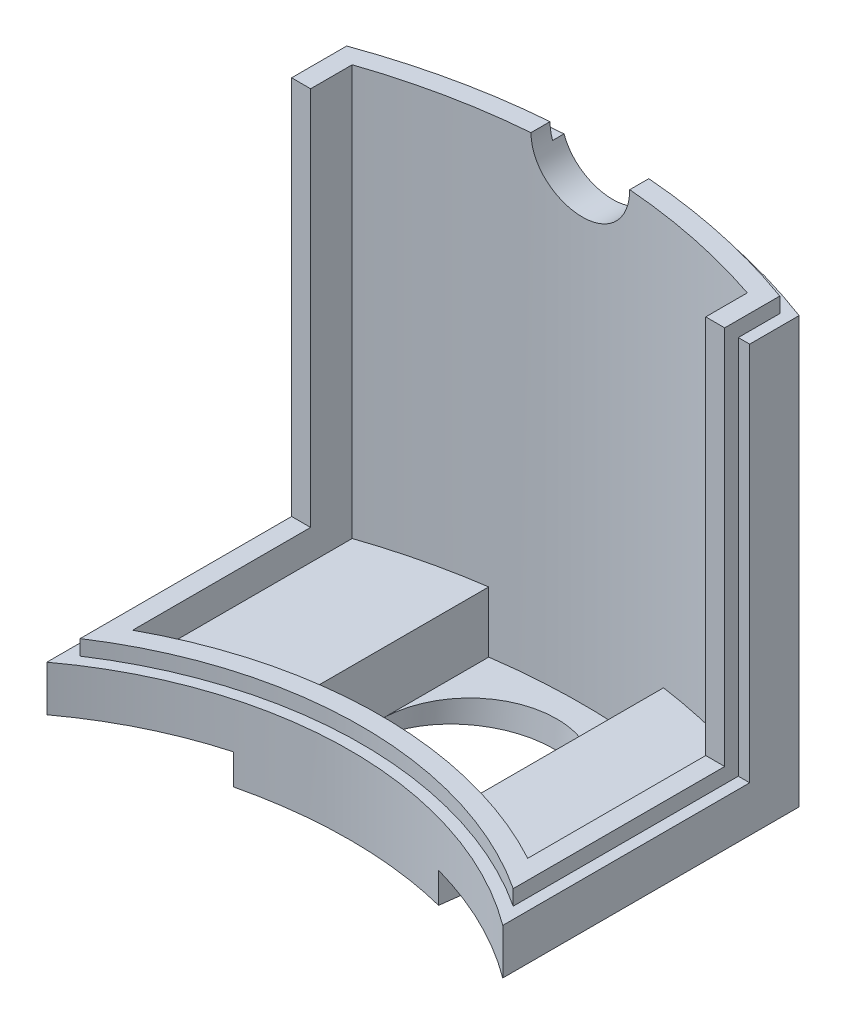
from build123d import *

# Parameters (mm, degrees)
BOSS_EXTRUDE2_DEPTH      = 2
BOSS_EXTRUDE4_DEPTH      = 4
CUT_EXTRUDE6_DEPTH       = 22.75
SKETCH4_R                = 5.75
CUT_EXTRUDE7_DEPTH       = 2
CUT_EXTRUDE8_DEPTH       = 4
BOSS_EXTRUDE5_DEPTH      = 27
BOSS_EXTRUDE6_DEPTH      = 2
BOSS_EXTRUDE7_DEPTH      = 2
BOSS_EXTRUDE8_DEPTH      = 25
CUT_EXTRUDE10_DEPTH      = 26
SKETCH14_R               = 3.25
CUT_EXTRUDE11_DEPTH      = 1
CUT_EXTRUDE11_DEPTH_BACK = 43.5
CUT_EXTRUDE12_DEPTH      = 1


with BuildPart() as part:
    # Sketch1 → Boss-Extrude2 (new body)
    with BuildSketch(Plane(origin=(0, 0, 0), x_dir=(1, 0, 0), z_dir=(0, 1, 0))):
        with BuildLine():
            Line((-15, 39.764934301), (-15, 20.264934301))
            ThreePointArc((-15, 20.264934301), (0, 25.212448557), (15, 20.264934301))
            Line((15, 20.264934301), (15, 39.764934301))
            ThreePointArc((15, 39.764934301), (0, 42.5), (-15, 39.764934301))
        make_face()
    extrude(amount=BOSS_EXTRUDE2_DEPTH)

    # Sketch2 → Boss-Extrude4 (add)
    with BuildSketch(Plane.XZ):
        with BuildLine():
            Line((6.75, -24.292078179), (6.75, -41.960546946))
            ThreePointArc((6.75, -41.960546946), (0, -42.5), (-6.75, -41.960546946))
            Line((-6.75, -41.960546946), (-6.75, -24.292078179))
            ThreePointArc((-6.75, -24.292078179), (0, -25.212448557), (6.75, -24.292078179))
        make_face()
    extrude(amount=BOSS_EXTRUDE4_DEPTH)

    # Sketch3 → Cut-Extrude6 (cut, through all)
    with BuildSketch(Plane(origin=(6.75, 0, 0), x_dir=(0, 0, -1), z_dir=(1, 0, 0))):
        Polygon((41.960546946, -4), (24.292078179, -2), (24.292078179, -4), align=None)
    extrude(amount=-CUT_EXTRUDE6_DEPTH, mode=Mode.SUBTRACT)

    # Sketch4 → Cut-Extrude7 (cut)
    with BuildSketch(Plane(origin=(0, 0.740280631, -0.083796807), x_dir=(-1, 0, 0), z_dir=(0, -0.993654251, 0.112477687))):
        with Locations((0, 33.039130231)):
            Circle(SKETCH4_R)
    extrude(amount=-CUT_EXTRUDE7_DEPTH, mode=Mode.SUBTRACT)

    # Sketch5 → Cut-Extrude8 (cut)
    with BuildSketch(Plane(origin=(0, 2, 0), x_dir=(1, 0, 0), z_dir=(0, 1, 0))):
        with BuildLine():
            ThreePointArc((-5.75, 40.089743077), (0, 40.5), (5.75, 40.089743077))
            Line((5.75, 40.089743077), (5.75, 26.598023544))
            ThreePointArc((5.75, 26.598023544), (0, 27.212448557), (-5.75, 26.598023544))
            Line((-5.75, 26.598023544), (-5.75, 40.089743077))
        make_face()
    extrude(amount=-CUT_EXTRUDE8_DEPTH, mode=Mode.SUBTRACT)

    # Sketch7 → Boss-Extrude5 (add)
    with BuildSketch(Plane(origin=(0, 2, 0), x_dir=(1, 0, 0), z_dir=(0, 1, 0))):
        with BuildLine():
            Line((-15, 37.619808612), (-15, 39.764934301))
            ThreePointArc((-15, 39.764934301), (0, 42.5), (15, 39.764934301))
            Line((15, 39.764934301), (15, 37.619808612))
            ThreePointArc((15, 37.619808612), (0, 40.5), (-15, 37.619808612))
        make_face()
    extrude(amount=BOSS_EXTRUDE5_DEPTH)

    # Sketch8 → Boss-Extrude6 (add)
    with BuildSketch(Plane(origin=(0, 2, 0), x_dir=(1, 0, 0), z_dir=(0, 1, 0))):
        with BuildLine():
            Line((-15, 22.7050073), (-15, 20.264934301))
            ThreePointArc((-15, 20.264934301), (0, 25.212448557), (15, 20.264934301))
            Line((15, 20.264934301), (15, 22.7050073))
            ThreePointArc((15, 22.7050073), (0, 27.212448557), (-15, 22.7050073))
        make_face()
    extrude(amount=BOSS_EXTRUDE6_DEPTH)

    # Sketch9 → Boss-Extrude7 (add)
    with BuildSketch(Plane(origin=(0, 2, 0), x_dir=(1, 0, 0), z_dir=(0, 1, 0))):
        with BuildLine():
            Line((-15, 37.619808612), (-15, 22.7050073))
            ThreePointArc((-15, 22.7050073), (-14.012881704, 23.32716234), (-13, 23.906429187))
            Line((-13, 23.906429187), (-13, 38.356876828))
            ThreePointArc((-13, 38.356876828), (-14.004849781, 38.001502373), (-15, 37.619808612))
        make_face()
    boss_extrude7 = extrude(amount=BOSS_EXTRUDE7_DEPTH)

    # Mirror1: Boss-Extrude7 across plane
    add(boss_extrude7.mirror(Plane(origin=(0, 0, 0), x_dir=(0, 0, 1), z_dir=(1, 0, 0))))

    # Sketch12 → Boss-Extrude8 (add)
    with BuildSketch(Plane(origin=(0, 4, 0), x_dir=(1, 0, 0), z_dir=(0, 1, 0))):
        with BuildLine():
            ThreePointArc((-13, 38.356876828), (-14.004849781, 38.001502373), (-15, 37.619808612))
            Line((-15, 37.619808612), (-15, 35.619808612))
            Line((-15, 35.619808612), (-13, 35.619808612))
            Line((-13, 35.619808612), (-13, 38.356876828))
        make_face()
        with BuildLine():
            Line((15, 35.619808612), (15, 37.619808612))
            ThreePointArc((15, 37.619808612), (14.004849781, 38.001502373), (13, 38.356876828))
            Line((13, 38.356876828), (13, 35.619808612))
            Line((13, 35.619808612), (15, 35.619808612))
        make_face()
    extrude(amount=BOSS_EXTRUDE8_DEPTH)

    # Sketch13 → Cut-Extrude10 (cut)
    with BuildSketch(Plane(origin=(0, 29, 0), x_dir=(1, 0, 0), z_dir=(0, 1, 0))):
        with BuildLine():
            Line((-14.25, 21.702217285), (-14.25, 36.513007281))
            Line((-14.25, 36.513007281), (-15, 36.513007281))
            Line((-15, 36.513007281), (-15, 20.264934301))
            ThreePointArc((-15, 20.264934301), (0, 25.212448557), (15, 20.264934301))
            Line((15, 20.264934301), (15, 36.513007281))
            Line((15, 36.513007281), (14.25, 36.513007281))
            Line((14.25, 36.513007281), (14.25, 21.702217285))
            ThreePointArc((14.25, 21.702217285), (0, 25.962448557), (-14.25, 21.702217285))
        make_face()
    extrude(amount=-CUT_EXTRUDE10_DEPTH, mode=Mode.SUBTRACT)

    # Sketch14 → Cut-Extrude11 (cut, two sides)
    with BuildSketch(Plane.XY) as cut_extrude11_sk:
        with Locations((0, 29)):
            Circle(SKETCH14_R)
    extrude(amount=CUT_EXTRUDE11_DEPTH, mode=Mode.SUBTRACT)
    extrude(cut_extrude11_sk.sketch, amount=-CUT_EXTRUDE11_DEPTH_BACK, mode=Mode.SUBTRACT)

    # Sketch15 → Cut-Extrude12 (cut)
    with BuildSketch(Plane(origin=(0, 29, 0), x_dir=(1, 0, 0), z_dir=(0, 1, 0))):
        with BuildLine():
            Line((-15, 36.513007281), (-15, 39.764934301))
            ThreePointArc((-15, 39.764934301), (0, 42.5), (15, 39.764934301))
            Line((15, 39.764934301), (15, 36.513007281))
            Line((15, 36.513007281), (14.25, 36.513007281))
            Line((14.25, 36.513007281), (14.25, 39.242833741))
            ThreePointArc((14.25, 39.242833741), (0, 41.75), (-14.25, 39.242833741))
            Line((-14.25, 39.242833741), (-14.25, 36.513007281))
            Line((-14.25, 36.513007281), (-15, 36.513007281))
        make_face()
    extrude(amount=-CUT_EXTRUDE12_DEPTH, mode=Mode.SUBTRACT)


solid = part.part
